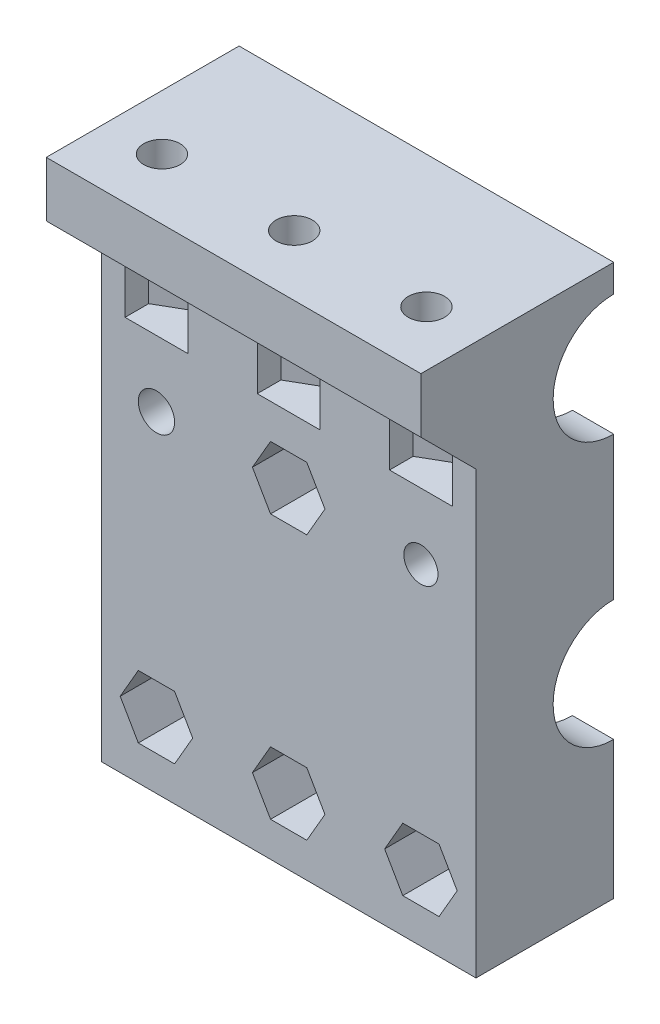
from build123d import *

# Parameters (mm, degrees)
SKETCH_1_W          = 12.5
SKETCH_1_H          = 50
EXTRUDE_1_DEPTH     = 34
SKETCH_2_R          = 7.5
CUT_EXTRUDE_1_DEPTH = 13.25
SKETCH_3_R          = 1.55
SKETCH_3_R_2        = 1.65
CUT_EXTRUDE_2_DEPTH = 13.5
CUT_EXTRUDE_3_DEPTH = 5
SKETCH_5_R          = 5.5
CUT_EXTRUDE_4_DEPTH = 35
EXTRUDE_2_DEPTH     = 17
SKETCH_7_R          = 1.65
CUT_EXTRUDE_5_DEPTH = 6
CUT_EXTRUDE_6_DEPTH = 9


with BuildPart() as part:
    # 草图1 → 凸台-拉伸1 (new body)
    with BuildSketch(Plane(origin=(0, 0, 0), x_dir=(0, 0, -1), z_dir=(1, 0, 0))):
        with Locations((6.25, 25)):
            Rectangle(SKETCH_1_W, SKETCH_1_H)
    extrude(amount=EXTRUDE_1_DEPTH)

    # 草图2 → 切除-拉伸1 (cut, symmetric)
    with BuildSketch(Plane.ZY.offset(-17)):
        with Locations((-12.5, 18)):
            Circle(SKETCH_2_R)
        with Locations((-12.5, 42)):
            Circle(SKETCH_2_R)
    extrude(amount=CUT_EXTRUDE_1_DEPTH, both=True, mode=Mode.SUBTRACT)

    # 草图3 → 切除-拉伸2 (cut, through all)
    with BuildSketch(Plane.XY):
        with Locations((29, 30)):
            Circle(SKETCH_3_R)
        with Locations((5, 30)):
            Circle(SKETCH_3_R_2)
        with Locations((17, 30)):
            Circle(SKETCH_3_R)
        with Locations((5, 6)):
            Circle(SKETCH_3_R_2)
        with Locations((17, 6)):
            Circle(SKETCH_3_R)
        with Locations((29, 6)):
            Circle(SKETCH_3_R)
    extrude(amount=-CUT_EXTRUDE_2_DEPTH, mode=Mode.SUBTRACT)

    # 草图4 → 切除-拉伸3 (cut)
    with BuildSketch(Plane.XY):
        Polygon((18.645448267, 27.15), (20.290896534, 30), (18.645448267, 32.85), (15.354551733, 32.85), (13.709103466, 30), (15.354551733, 27.15), align=None)
        Polygon((18.645448267, 3.15), (20.290896534, 6), (18.645448267, 8.85), (15.354551733, 8.85), (13.709103466, 6), (15.354551733, 3.15), align=None)
        Polygon((30.645448267, 3.15), (32.290896534, 6), (30.645448267, 8.85), (27.354551733, 8.85), (25.709103466, 6), (27.354551733, 3.15), align=None)
        Polygon((6.645448267, 3.15), (8.290896534, 6), (6.645448267, 8.85), (3.354551733, 8.85), (1.709103466, 6), (3.354551733, 3.15), align=None)
    extrude(amount=-CUT_EXTRUDE_3_DEPTH, mode=Mode.SUBTRACT)

    # 草图5 → 切除-拉伸4 (cut, through all)
    with BuildSketch(Plane(origin=(34, 0, 0), x_dir=(0, 0, -1), z_dir=(1, 0, 0))):
        with Locations((12.5, 18)):
            Circle(SKETCH_5_R)
        with Locations((12.5, 42)):
            Circle(SKETCH_5_R)
    extrude(amount=-CUT_EXTRUDE_4_DEPTH, mode=Mode.SUBTRACT)

    # 草图6 → 凸台-拉伸2 (add, symmetric)
    with BuildSketch(Plane.ZY.offset(-17)):
        Polygon((0, 50), (5, 50), (5, 45), (0, 40), align=None)
    extrude(amount=EXTRUDE_2_DEPTH, both=True)

    # 草图7 → 切除-拉伸5 (cut, through all)
    with BuildSketch(Plane(origin=(0, 45, 0), x_dir=(1, 0, 0), z_dir=(0, 1, 0))):
        with Locations((5, 0.5)):
            Circle(SKETCH_7_R)
        with Locations((17, 0.5)):
            Circle(SKETCH_7_R)
        with Locations((29, 0.5)):
            Circle(SKETCH_7_R)
    extrude(amount=CUT_EXTRUDE_5_DEPTH, mode=Mode.SUBTRACT)

    # 草图8 → 切除-拉伸6 (cut)
    with BuildSketch(Plane(origin=(0, 45, 0), x_dir=(1, 0, 0), z_dir=(0, 1, 0))):
        Polygon((7.85, -0.590838694), (7.85, 2.145448267), (5, 3.790896534), (2.15, 2.145448267), (2.15, -0.481963635), (2.15, -5), (7.85, -5), align=None)
        Polygon((19.85, -0.590838694), (19.85, 2.145448267), (17, 3.790896534), (14.15, 2.145448267), (14.15, -0.481963635), (14.15, -5), (19.85, -5), align=None)
        Polygon((31.85, -0.590838694), (31.85, 2.145448267), (29, 3.790896534), (26.15, 2.145448267), (26.15, -0.481963635), (26.15, -5), (31.85, -5), align=None)
    extrude(amount=-CUT_EXTRUDE_6_DEPTH, mode=Mode.SUBTRACT)


solid = part.part
